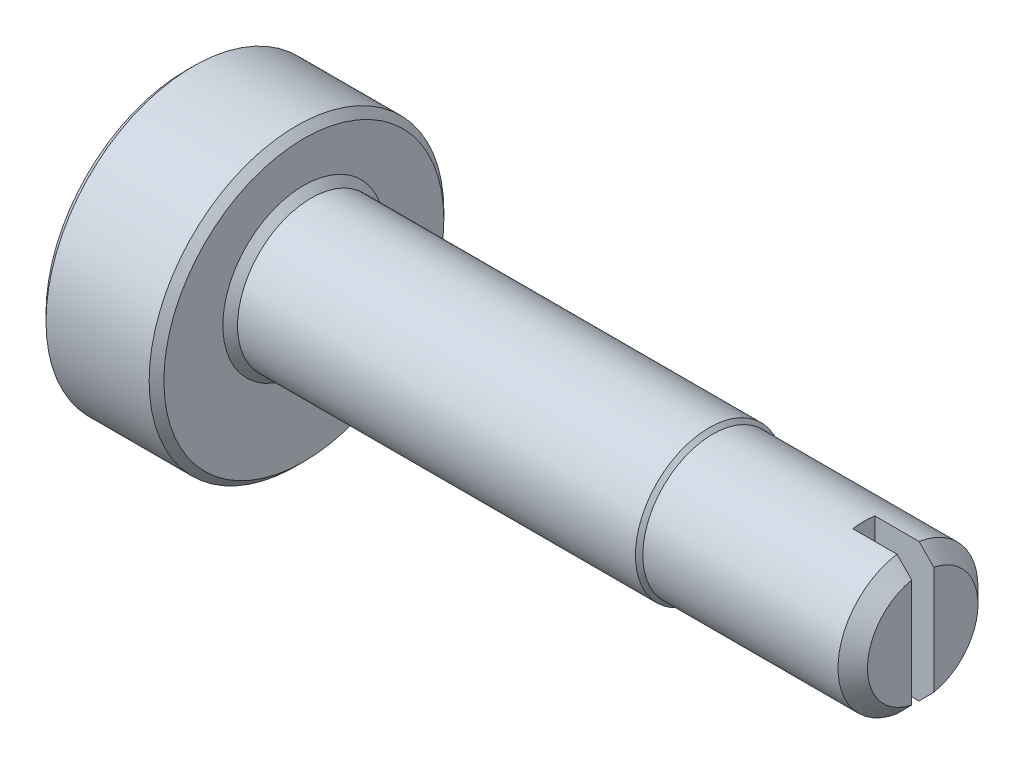
from build123d import *

# Parameters (mm, degrees)
CUT_EXTRUDE_5_REACH      = 12
SKETCH_2_R               = 2.5
SKETCH_2_R_2             = 2
CUT_EXTRUDE_8_DEPTH      = 0.8
CHAMFER_1_SIZE           = 0.2
CHAMFER_2_SIZE           = 0.1
SKETCH_4_R               = 3.825
CUT_EXTRUDE_9_DEPTH      = 0.25
CUT_EXTRUDE_9_DEPTH_BACK = 0.25


with BuildPart() as part:
    # Эскиз1 → Повернуть1 (revolve)
    with BuildSketch(Plane.XY):
        Polygon((0, 0), (0, 2.5), (1.6, 2.5), (1.6, 1.1), (1.7, 1), (7.1, 1), (7.15, 0.95), (10, 0.95), (10, 0), align=None)
    revolve(axis=Axis((0, 0, 0), (-1, 0, 0)))

    # Эскиз2 → Вырез-Вытянуть5 (cut, up to next)
    with BuildSketch(Plane.ZY, mode=Mode.PRIVATE) as cut_extrude_5_sk1:
        Circle(SKETCH_2_R)
        with Locations((0, -0.25)):
            Circle(SKETCH_2_R_2, mode=Mode.SUBTRACT)
    cut_extrude_5_tool1 = extrude(cut_extrude_5_sk1.sketch, amount=-CUT_EXTRUDE_5_REACH, mode=Mode.PRIVATE) & part.part
    add(cut_extrude_5_tool1.solids().sort_by_distance((0, 0, -2.429289))[0], mode=Mode.SUBTRACT)

    # Эскиз3 → Вырез-Вытянуть8 (cut)
    with BuildSketch(Plane(origin=(10, 0, 0), x_dir=(0, 0, -1), z_dir=(1, 0, 0))):
        with BuildLine():
            ThreePointArc((0.15, 0.938083152), (0, 0.95), (-0.15, 0.938083152))
            Line((-0.15, 0.938083152), (-0.15, -0.938083152))
            ThreePointArc((-0.15, -0.938083152), (0, -0.95), (0.15, -0.938083152))
            Line((0.15, -0.938083152), (0.15, 0.938083152))
        make_face()
    extrude(amount=-CUT_EXTRUDE_8_DEPTH, mode=Mode.SUBTRACT)

    # Фаска1
    chamfer_1_edges = [part.edges().sort_by_distance(p)[0] for p in [
        (10, 0, 0.95),
        (10, 0, -0.95),
    ]]
    chamfer(chamfer_1_edges, length=CHAMFER_1_SIZE)

    # Фаска2
    chamfer_2_edges = [part.edges().sort_by_distance(p)[0] for p in [
        (0, -0.25, -2),
        (1.6, -0.25, -2),
    ]]
    chamfer(chamfer_2_edges, length=CHAMFER_2_SIZE)

    # Эскиз4 → Вырез-Вытянуть9 (cut, two sides)
    with BuildSketch(Plane.XY) as cut_extrude_9_sk:
        with Locations((-3.425, -0.25)):
            Circle(SKETCH_4_R)
    extrude(amount=CUT_EXTRUDE_9_DEPTH, mode=Mode.SUBTRACT)
    extrude(cut_extrude_9_sk.sketch, amount=-CUT_EXTRUDE_9_DEPTH_BACK, mode=Mode.SUBTRACT)


solid = part.part
